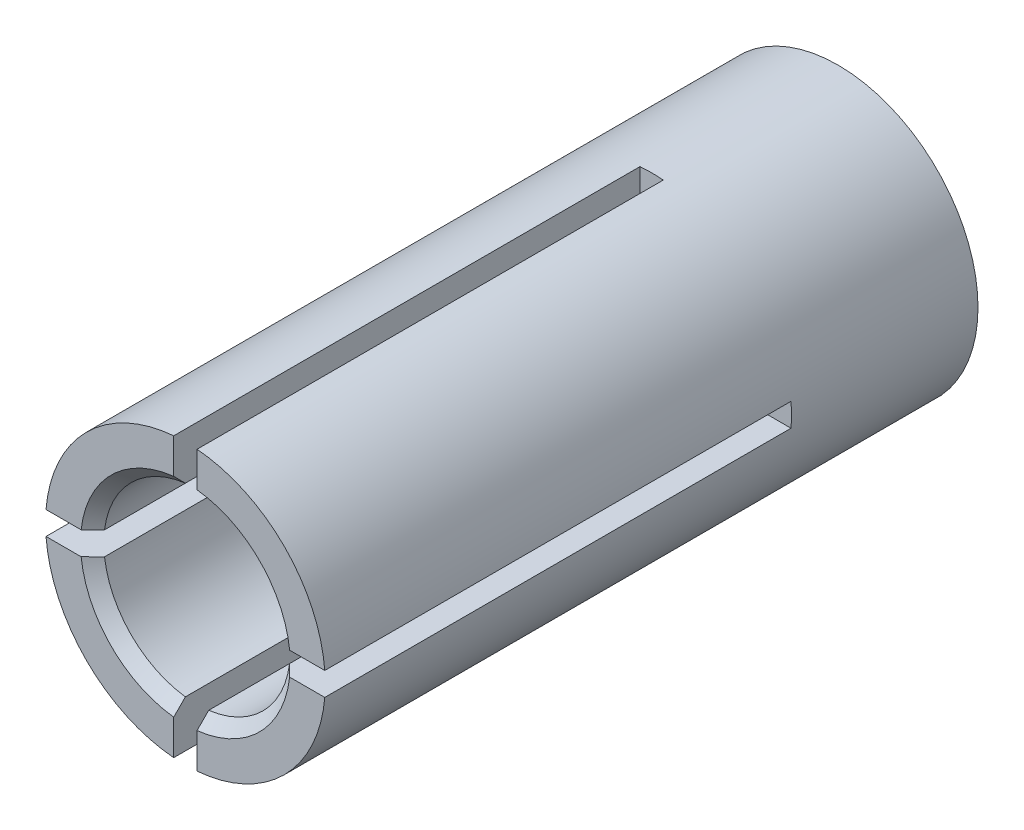
from build123d import *

# Parameters (mm, degrees)
ESQUISSE1_R             = 3
ESQUISSE1_R_2           = 2
EXTRUSION1_DEPTH        = 14
CHANFREIN1_SIZE         = 0.25
ENL_V_MAT_EXTRU_1_DEPTH = 10


with BuildPart() as part:
    # Esquisse1 → Extrusion1 (new body)
    with BuildSketch(Plane.XY):
        Circle(ESQUISSE1_R)
        Circle(ESQUISSE1_R_2, mode=Mode.SUBTRACT)
    extrude(amount=EXTRUSION1_DEPTH)

    # Chanfrein1
    chanfrein1_edges = [part.edges().sort_by_distance(p)[0] for p in [
        (-2, 0, 14),
    ]]
    chamfer(chanfrein1_edges, length=CHANFREIN1_SIZE)

    # Esquisse4 → Enlèv. mat.-Extru.1 (cut)
    with BuildSketch(Plane.XY.offset(14)):
        with BuildLine():
            Line((0.25, 2.989565186), (0.25, 0.25))
            Line((0.25, 0.25), (2.989565186, 0.25))
            ThreePointArc((2.989565186, 0.25), (3, 0), (2.989565186, -0.25))
            Line((2.989565186, -0.25), (0.25, -0.25))
            Line((0.25, -0.25), (0.25, -2.989565186))
            ThreePointArc((0.25, -2.989565186), (0, -3), (-0.25, -2.989565186))
            Line((-0.25, -2.989565186), (-0.25, -0.25))
            Line((-0.25, -0.25), (-2.989565186, -0.25))
            ThreePointArc((-2.989565186, -0.25), (-3, 0), (-2.989565186, 0.25))
            Line((-2.989565186, 0.25), (-0.25, 0.25))
            Line((-0.25, 0.25), (-0.25, 2.989565186))
            ThreePointArc((-0.25, 2.989565186), (0, 3), (0.25, 2.989565186))
        make_face()
    extrude(amount=-ENL_V_MAT_EXTRU_1_DEPTH, mode=Mode.SUBTRACT)


solid = part.part
